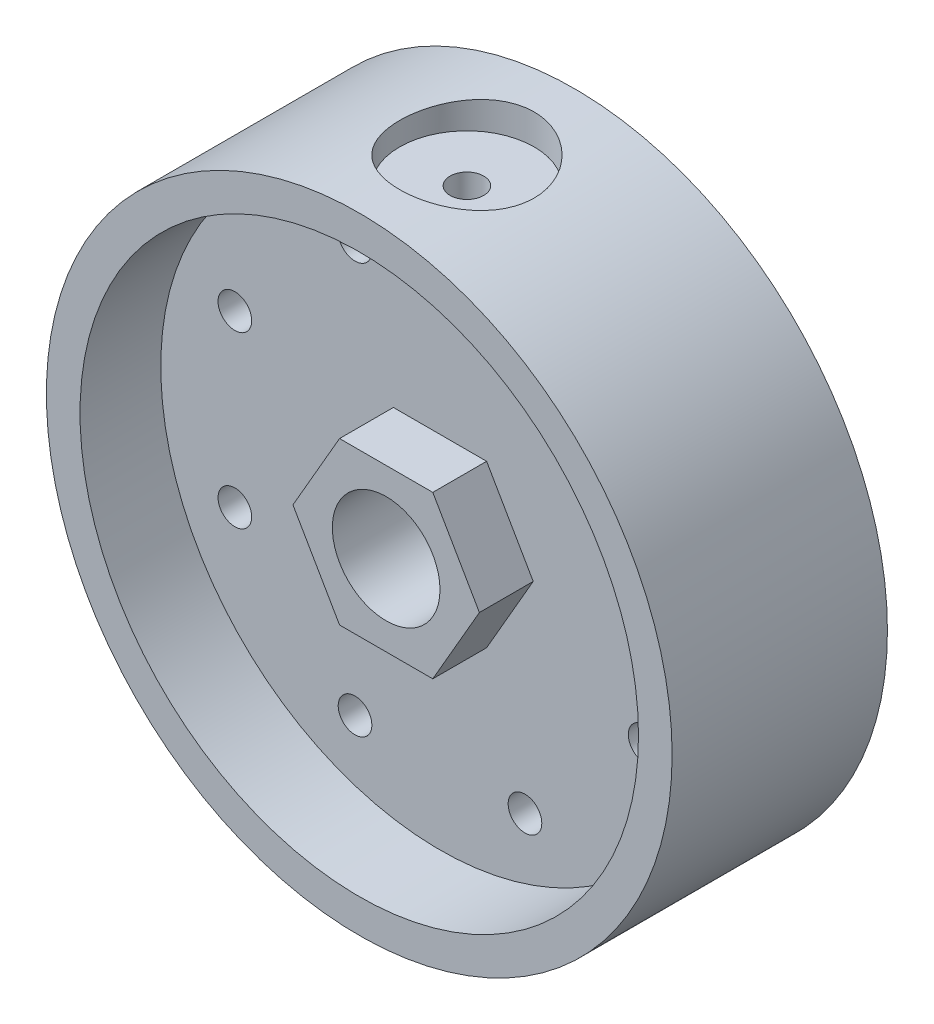
from build123d import *

# Parameters (mm, degrees)
ESQUISSE1_R           = 23.25
ESQUISSE1_R_2         = 20.75
MAIN_DEPTH            = 8
ESQUISSE2_R           = 20.75
CENTRALPART_DEPTH     = 2
HEXAGONAL_DEPTH       = 6
ESQUISSE5_R           = 4
CENTRALHOLE_DEPTH     = 6
FIXTOPHOLE_DEPTH      = 51.622376475
FIXTOPHOLE_DEPTH_BACK = 22
SKETCH1_R             = 1.25
SKETCH2_R             = 5
CUT_EXTRUDE2_DEPTH    = 51.622376624
SKETCH3_R             = 1.25
HUBFIXHOLE_DEPTH      = 34.839695786
CIRPATTERN1_COUNT     = 8


with BuildPart() as part:
    # Esquisse1 → Main (new, symmetric)
    with BuildSketch(Plane.XY):
        Circle(ESQUISSE1_R)
        Circle(ESQUISSE1_R_2, mode=Mode.SUBTRACT)
    extrude(amount=MAIN_DEPTH, both=True)

    # Esquisse2 → CentralPart (add, symmetric)
    with BuildSketch(Plane.XY):
        Circle(ESQUISSE2_R)
    extrude(amount=CENTRALPART_DEPTH, both=True)

    # Esquisse3 → Hexagonal (add)
    with BuildSketch(Plane.XY):
        Polygon((-3.464101615, 6), (-6.92820323, 0), (-3.464101615, -6), (3.464101615, -6), (6.92820323, 0), (3.464101615, 6), align=None)
    extrude(amount=HEXAGONAL_DEPTH)

    # Esquisse5 → CentralHole (cut, symmetric)
    with BuildSketch(Plane.XY):
        Circle(ESQUISSE5_R)
    extrude(amount=CENTRALHOLE_DEPTH, both=True, mode=Mode.SUBTRACT)

    # Sketch1 → FixTopHole (cut, two sides: drawn at the far end of the back side and taken through both)
    with BuildSketch(Plane(origin=(0, 21, 0), x_dir=(1, 0, 0), z_dir=(0, 1, 0)).offset(-FIXTOPHOLE_DEPTH_BACK)):
        Circle(SKETCH1_R)
    extrude(amount=FIXTOPHOLE_DEPTH + FIXTOPHOLE_DEPTH_BACK, mode=Mode.SUBTRACT)

    # Sketch2 → Cut-Extrude2 (cut, through all)
    with BuildSketch(Plane(origin=(0, 21, 0), x_dir=(1, 0, 0), z_dir=(0, 1, 0))):
        Circle(SKETCH2_R)
    extrude(amount=CUT_EXTRUDE2_DEPTH, mode=Mode.SUBTRACT)

    # Sketch3 → HubFixHole (cut, symmetric)
    with BuildSketch(Plane.XY):
        with Locations((-6.314276634, 15.244012286)):
            Circle(SKETCH3_R)
    hubfixhole = extrude(amount=HUBFIXHOLE_DEPTH, both=True, mode=Mode.SUBTRACT)

    # CirPattern1: HubFixHole ×8 about axis
    cirpattern1_axis = Axis((0, 0, -6.6), (0, 0, 1))
    for i in range(1, CIRPATTERN1_COUNT):
        add(hubfixhole.rotate(cirpattern1_axis, i * 360 / CIRPATTERN1_COUNT), mode=Mode.SUBTRACT)


solid = part.part
